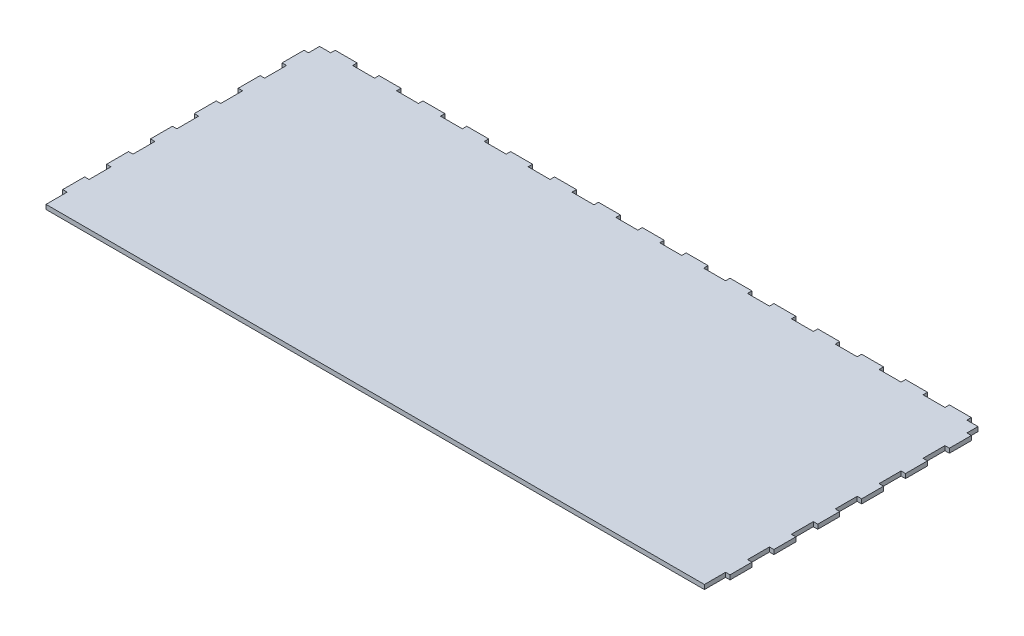
from build123d import *

# Parameters (mm, degrees)
BOSS_EXTRUDE1_DEPTH = 4


with BuildPart() as part:
    # Sketch1 → Boss-Extrude1 (new body)
    with BuildSketch(Plane(origin=(0, 0, 0), x_dir=(1, 0, 0), z_dir=(0, 1, 0))):
        Polygon((9.8625, 250), (-9.8625, 250), (-9.8625, 246), (-29.5875, 246), (-29.5875, 250), (-49.3125, 250), (-49.3125, 246), (-69.0375, 246), (-69.0375, 250), (-88.7625, 250), (-88.7625, 246), (-108.4875, 246), (-108.4875, 250), (-128.2125, 250), (-128.2125, 246), (-147.9375, 246), (-147.9375, 250), (-167.6625, 250), (-167.6625, 246), (-187.3875, 246), (-187.3875, 250), (-207.1125, 250), (-207.1125, 246), (-226.8375, 246), (-226.8375, 250), (-246.5625, 250), (-246.5625, 246), (-266.2875, 246), (-266.2875, 250), (-286.0125, 250), (-286.0125, 246), (-296.0125, 246), (-296.0125, 236), (-300.0125, 236), (-300.0125, 216.275), (-296.0125, 216.275), (-296.0125, 196.55), (-300.0125, 196.55), (-300.0125, 176.825), (-296.0125, 176.825), (-296.0125, 157.1), (-300.0125, 157.1), (-300.0125, 137.375), (-296.0125, 137.375), (-296.0125, 117.65), (-300.0125, 117.65), (-300.0125, 97.925), (-296.0125, 97.925), (-296.0125, 78.2), (-300.0125, 78.2), (-300.0125, 58.475), (-296.0125, 58.475), (-296.0125, 38.75), (-300.0125, 38.75), (-300.0125, 19.025), (-296.0125, 19.025), (-296.0125, 0), (296.0125, 0), (296.0125, 19.025), (300.0125, 19.025), (300.0125, 38.75), (296.0125, 38.75), (296.0125, 58.475), (300.0125, 58.475), (300.0125, 78.2), (296.0125, 78.2), (296.0125, 97.925), (300.0125, 97.925), (300.0125, 117.65), (296.0125, 117.65), (296.0125, 137.375), (300.0125, 137.375), (300.0125, 157.1), (296.0125, 157.1), (296.0125, 176.825), (300.0125, 176.825), (300.0125, 196.55), (296.0125, 196.55), (296.0125, 216.275), (300.0125, 216.275), (300.0125, 236), (296.0125, 236), (296.0125, 246), (286.0125, 246), (286.0125, 250), (266.2875, 250), (266.2875, 246), (246.5625, 246), (246.5625, 250), (226.8375, 250), (226.8375, 246), (207.1125, 246), (207.1125, 250), (187.3875, 250), (187.3875, 246), (167.6625, 246), (167.6625, 250), (147.9375, 250), (147.9375, 246), (128.2125, 246), (128.2125, 250), (108.4875, 250), (108.4875, 246), (88.7625, 246), (88.7625, 250), (69.0375, 250), (69.0375, 246), (49.3125, 246), (49.3125, 250), (29.5875, 250), (29.5875, 246), (9.8625, 246), align=None)
    extrude(amount=BOSS_EXTRUDE1_DEPTH)


solid = part.part
